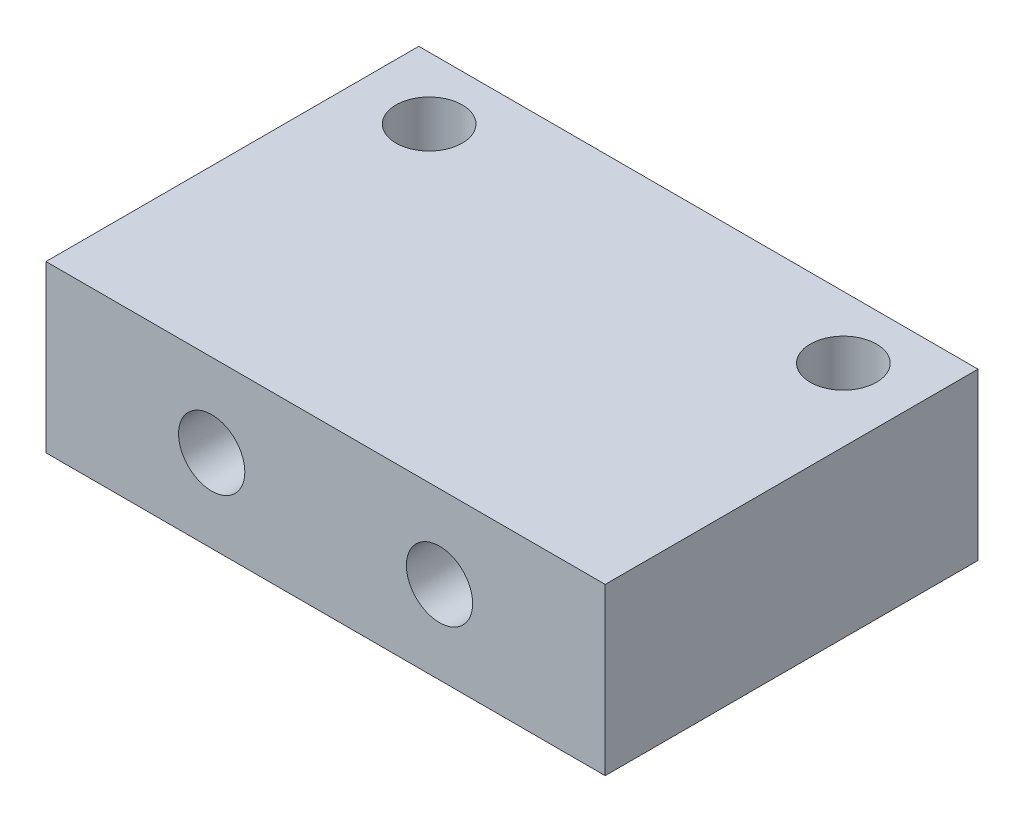
from build123d import *

# Parameters (mm, degrees)
SKETCH1_W               = 27
SKETCH1_H               = 6
SKETCH1_R               = 1.6
BOSS_EXTRUDE1_DEPTH     = 8
SKETCH3_W               = 27
SKETCH3_H               = 8
BOSS_EXTRUDE2_DEPTH     = 12
SKETCH2_R               = 1.6
CUT_EXTRUDE1_DEPTH      = 16
CUT_EXTRUDE1_DEPTH_BACK = 4


with BuildPart() as part:
    # Sketch1 → Boss-Extrude1 (new body)
    with BuildSketch(Plane(origin=(0, 0, 0), x_dir=(1, 0, 0), z_dir=(0, 1, 0))):
        with Locations((10, 0)):
            Rectangle(SKETCH1_W, SKETCH1_H)
        Circle(SKETCH1_R, mode=Mode.SUBTRACT)
        with Locations((20, 0)):
            Circle(SKETCH1_R, mode=Mode.SUBTRACT)
    extrude(amount=BOSS_EXTRUDE1_DEPTH)

    # Sketch3 → Boss-Extrude2 (add)
    with BuildSketch(Plane.XY.offset(3)):
        with Locations((10, 4)):
            Rectangle(SKETCH3_W, SKETCH3_H)
    extrude(amount=BOSS_EXTRUDE2_DEPTH)

    # Sketch2 → Cut-Extrude1 (cut, two sides)
    with BuildSketch(Plane.XY) as cut_extrude1_sk:
        with Locations((4.5, 4)):
            Circle(SKETCH2_R)
        with Locations((15.5, 4)):
            Circle(SKETCH2_R)
    extrude(amount=CUT_EXTRUDE1_DEPTH, mode=Mode.SUBTRACT)
    extrude(cut_extrude1_sk.sketch, amount=-CUT_EXTRUDE1_DEPTH_BACK, mode=Mode.SUBTRACT)


solid = part.part
